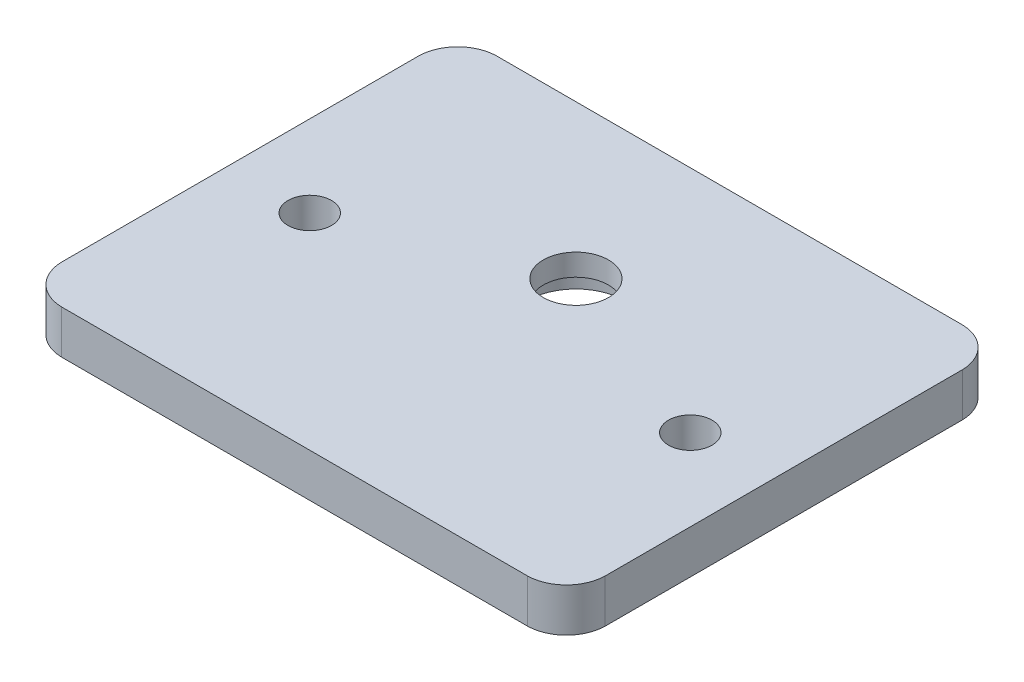
from build123d import *

# Parameters (mm, degrees)
SKETCH1_R           = 2
BOSS_EXTRUDE2_DEPTH = 4
SKETCH1_14_R        = 3
CUT_EXTRUDE2_DEPTH  = 33.26453161
SKETCH1_15_R        = 4.5
CUT_EXTRUDE3_DEPTH  = 2


with BuildPart() as part:
    # Sketch1 → Boss-Extrude2 (new body)
    with BuildSketch(Plane(origin=(0, 0, 0), x_dir=(1, 0, 0), z_dir=(0, 1, 0))):
        with BuildLine():
            Line((21.446973136, 20), (-21.446973136, 20))
            ThreePointArc((-21.446973136, 20), (-23.935145745, 18.935145745), (-25, 16.446973136))
            Line((-25, 16.446973136), (-25, -16.446973136))
            ThreePointArc((-25, -16.446973136), (-23.935145745, -18.935145745), (-21.446973136, -20))
            Line((-21.446973136, -20), (21.446973136, -20))
            ThreePointArc((21.446973136, -20), (23.935145745, -18.935145745), (25, -16.446973136))
            Line((25, -16.446973136), (25, 16.446973136))
            ThreePointArc((25, 16.446973136), (23.935145745, 18.935145745), (21.446973136, 20))
        make_face()
        with Locations((-17.5, -1.102660735)):
            Circle(SKETCH1_R, mode=Mode.SUBTRACT)
        with Locations((17.5, -1.102660735)):
            Circle(SKETCH1_R, mode=Mode.SUBTRACT)
    extrude(amount=BOSS_EXTRUDE2_DEPTH)

    # Sketch1_14 → Cut-Extrude2 (cut, through all)
    with BuildSketch(Plane(origin=(0, 0, 0), x_dir=(1, 0, 0), z_dir=(0, 1, 0))):
        with Locations((-0.021660512, 5.8998827)):
            Circle(SKETCH1_14_R)
    extrude(amount=CUT_EXTRUDE2_DEPTH, mode=Mode.SUBTRACT)

    # Sketch1_15 → Cut-Extrude3 (cut)
    with BuildSketch(Plane(origin=(0, 0, 0), x_dir=(1, 0, 0), z_dir=(0, 1, 0))):
        with Locations((-0.021660512, 5.8998827)):
            Circle(SKETCH1_15_R)
    extrude(amount=CUT_EXTRUDE3_DEPTH, mode=Mode.SUBTRACT)


solid = part.part
